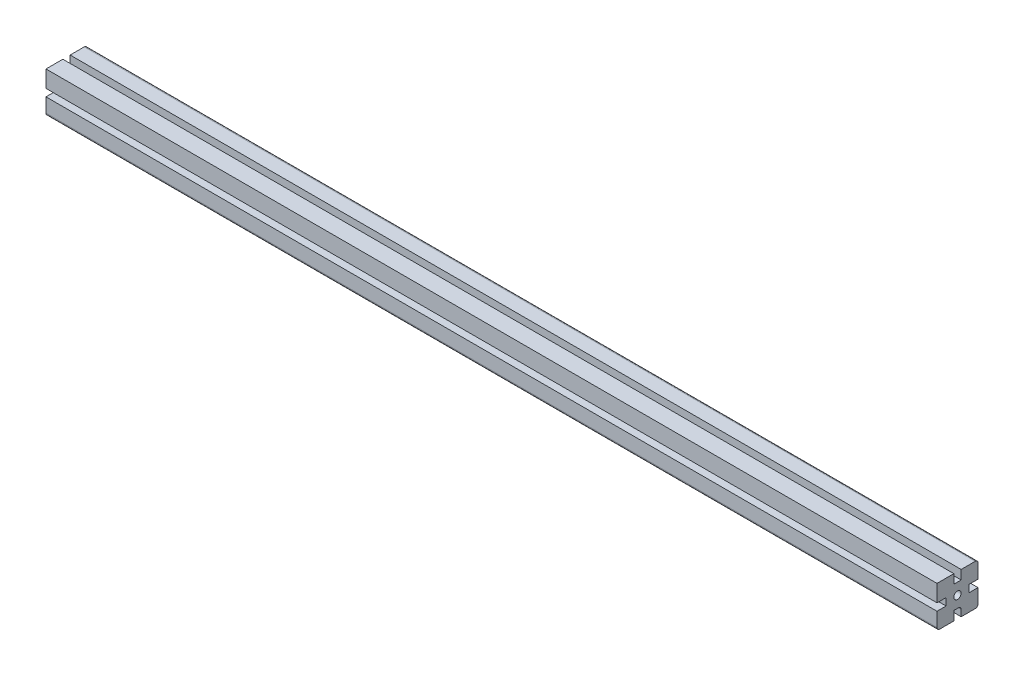
from build123d import *

# Parameters (mm, degrees)
ESQUISSE1_R        = 4
BOSS_EXTRU_1_DEPTH = 978
CONG_1_R           = 3


with BuildPart() as part:
    # Esquisse1 → Boss.-Extru.1 (new body)
    with BuildSketch(Plane(origin=(1000, 0, 0), x_dir=(0, 0, -1), z_dir=(1, 0, 0))):
        Polygon((22.5, -4), (12.5, -4), (12.5, 4), (22.5, 4), (22.5, 22.5), (4, 22.5), (4, 12.5), (-4, 12.5), (-4, 22.5), (-22.5, 22.5), (-22.5, 4), (-12.5, 4), (-12.5, -4), (-22.5, -4), (-22.5, -22.5), (-4, -22.5), (-4, -12.5), (4, -12.5), (4, -22.5), (22.5, -22.5), align=None)
        Circle(ESQUISSE1_R, mode=Mode.SUBTRACT)
    extrude(amount=-BOSS_EXTRU_1_DEPTH)

    # Congé1
    cong_1_edges = [part.edges().sort_by_distance(p)[0] for p in [
        (511, -22.5, -22.5),
        (511, -12.5, -4),
        (511, -22.5, 22.5),
        (511, 22.5, -22.5),
    ]]
    fillet(cong_1_edges, radius=CONG_1_R)


solid = part.part
